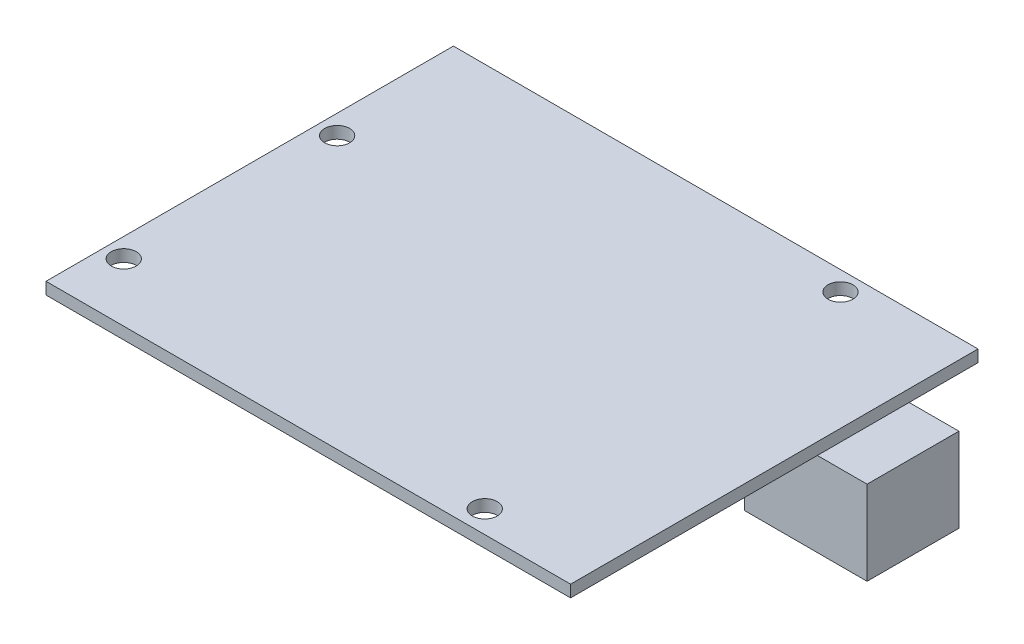
from build123d import *

# Parameters (mm, degrees)
SKETCH1_W           = 68.58
SKETCH1_H           = 53.26
SKETCH1_R           = 1.63195
BOSS_EXTRUDE1_DEPTH = 1.56
SKETCH2_W           = 16
SKETCH2_H           = 12
BOSS_EXTRUDE2_DEPTH = 11


with BuildPart() as part:
    # Sketch1 → Boss-Extrude1 (new body)
    with BuildSketch(Plane(origin=(0, 0, 0), x_dir=(1, 0, 0), z_dir=(0, 1, 0))):
        with Locations((31.75, 19.01)):
            Rectangle(SKETCH1_W, SKETCH1_H)
        Circle(SKETCH1_R, mode=Mode.SUBTRACT)
        with Locations((0, 27.9)):
            Circle(SKETCH1_R, mode=Mode.SUBTRACT)
        with Locations((51.9, -4.7)):
            Circle(SKETCH1_R, mode=Mode.SUBTRACT)
        with Locations((50.6, 43.1)):
            Circle(SKETCH1_R, mode=Mode.SUBTRACT)
    extrude(amount=BOSS_EXTRUDE1_DEPTH)

    # Sketch2 → Boss-Extrude2 (add)
    with BuildSketch(Plane(origin=(0, 0, 0), x_dir=(-1, 0, 0), z_dir=(0, -1, 0))):
        with Locations((-64.54, 30.64)):
            Rectangle(SKETCH2_W, SKETCH2_H)
    extrude(amount=BOSS_EXTRUDE2_DEPTH)


solid = part.part
